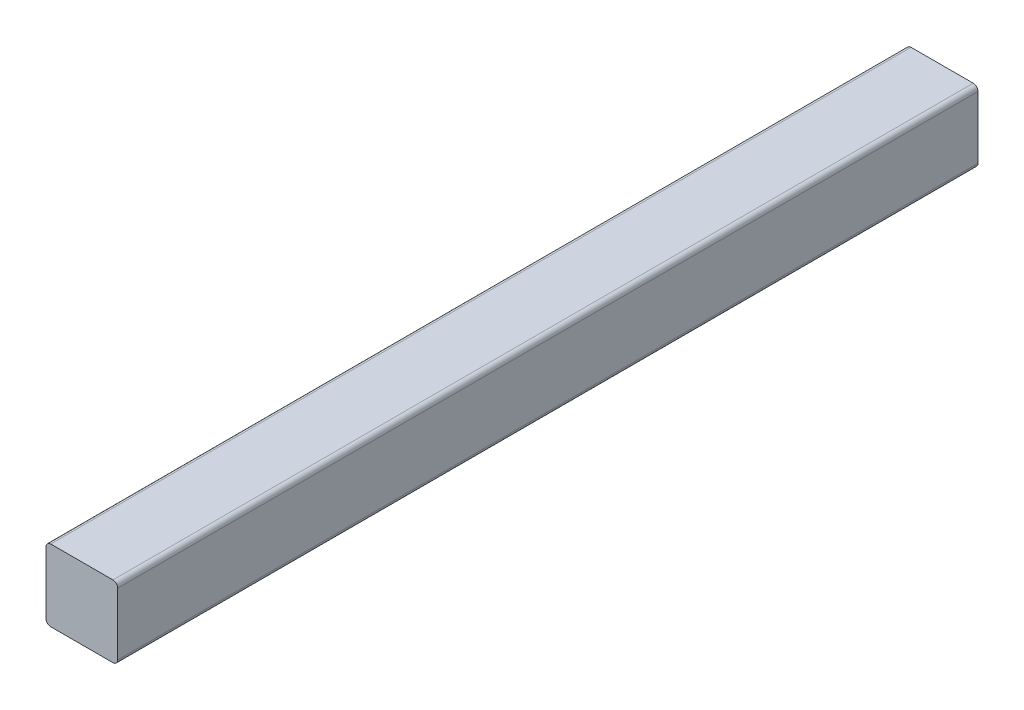
from build123d import *

# Parameters (mm, degrees)
BOSS_EXTRUDE1_DEPTH = 360


with BuildPart() as part:
    # Sketch3 → Boss-Extrude1 (new body)
    with BuildSketch(Plane.XY):
        with BuildLine():
            Line((2, 0), (28, 0))
            ThreePointArc((28, 0), (29.414213562, 0.585786438), (30, 2))
            Line((30, 2), (30, 28))
            ThreePointArc((30, 28), (29.414213562, 29.414213562), (28, 30))
            Line((28, 30), (2, 30))
            ThreePointArc((2, 30), (0.585786438, 29.414213562), (0, 28))
            Line((0, 28), (0, 2))
            ThreePointArc((0, 2), (0.585786438, 0.585786438), (2, 0))
        make_face()
    extrude(amount=BOSS_EXTRUDE1_DEPTH)


solid = part.part
